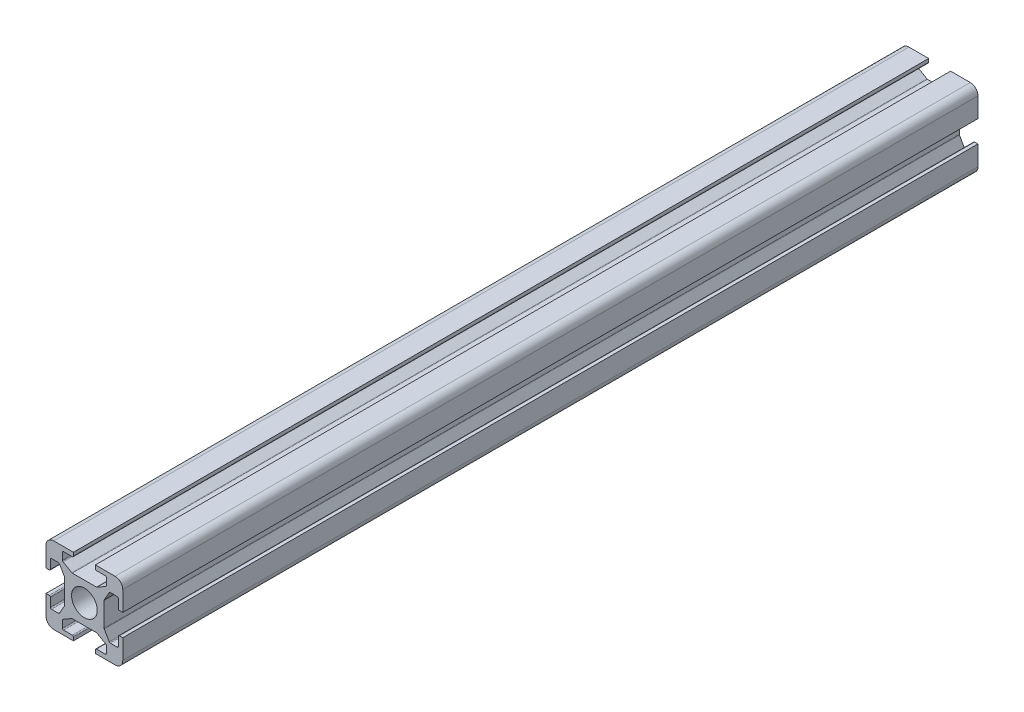
from build123d import *

# Parameters (mm, degrees)
CROQUIS1_R              = 5.85
SALIENTE_EXTRUIR1_DEPTH = 390


with BuildPart() as part:
    # Croquis1 → Saliente-Extruir1 (new body)
    with BuildSketch(Plane.XY):
        with BuildLine():
            Line((-17.5, -5), (-16, -5))
            ThreePointArc((-16, -5), (-15.646446609, -5.146446609), (-15.5, -5.5))
            Line((-15.5, -5.5), (-15.5, -9.5))
            ThreePointArc((-15.5, -9.5), (-15.353553391, -9.853553391), (-15, -10))
            Line((-15, -10), (-11.790147321, -10))
            ThreePointArc((-11.790147321, -10), (-11.539192936, -9.932460283), (-11.356036103, -9.748087586))
            Line((-11.356036103, -9.748087586), (-9.065888782, -5.740718013))
            ThreePointArc((-9.065888782, -5.740718013), (-9.016752854, -5.620974478), (-9, -5.492630427))
            Line((-9, -5.492630427), (-9, 5.492630427))
            ThreePointArc((-9, 5.492630427), (-9.016752854, 5.620974478), (-9.065888782, 5.740718013))
            Line((-9.065888782, 5.740718013), (-11.356036103, 9.748087586))
            ThreePointArc((-11.356036103, 9.748087586), (-11.539192936, 9.932460283), (-11.790147321, 10))
            Line((-11.790147321, 10), (-15, 10))
            ThreePointArc((-15, 10), (-15.353553391, 9.853553391), (-15.5, 9.5))
            Line((-15.5, 9.5), (-15.5, 5.5))
            ThreePointArc((-15.5, 5.5), (-15.646446609, 5.146446609), (-16, 5))
            Line((-16, 5), (-17.5, 5))
            Line((-17.5, 5), (-17.5, 14))
            ThreePointArc((-17.5, 14), (-16.474873734, 16.474873734), (-14, 17.5))
            Line((-14, 17.5), (-5, 17.5))
            Line((-5, 17.5), (-5, 16))
            ThreePointArc((-5, 16), (-5.146446609, 15.646446609), (-5.5, 15.5))
            Line((-5.5, 15.5), (-9.5, 15.5))
            ThreePointArc((-9.5, 15.5), (-9.853553391, 15.353553391), (-10, 15))
            Line((-10, 15), (-10, 11.790147321))
            ThreePointArc((-10, 11.790147321), (-9.932460283, 11.539192936), (-9.748087586, 11.356036103))
            Line((-9.748087586, 11.356036103), (-5.740718013, 9.065888782))
            ThreePointArc((-5.740718013, 9.065888782), (-5.620974478, 9.016752854), (-5.492630427, 9))
            Line((-5.492630427, 9), (5.492630427, 9))
            ThreePointArc((5.492630427, 9), (5.620974478, 9.016752854), (5.740718013, 9.065888782))
            Line((5.740718013, 9.065888782), (9.748087586, 11.356036103))
            ThreePointArc((9.748087586, 11.356036103), (9.932460283, 11.539192936), (10, 11.790147321))
            Line((10, 11.790147321), (10, 15))
            ThreePointArc((10, 15), (9.853553391, 15.353553391), (9.5, 15.5))
            Line((9.5, 15.5), (5.5, 15.5))
            ThreePointArc((5.5, 15.5), (5.146446609, 15.646446609), (5, 16))
            Line((5, 16), (5, 17.5))
            Line((5, 17.5), (14, 17.5))
            ThreePointArc((14, 17.5), (16.474873734, 16.474873734), (17.5, 14))
            Line((17.5, 14), (17.5, 5))
            Line((17.5, 5), (16, 5))
            ThreePointArc((16, 5), (15.646446609, 5.146446609), (15.5, 5.5))
            Line((15.5, 5.5), (15.5, 9.5))
            ThreePointArc((15.5, 9.5), (15.353553391, 9.853553391), (15, 10))
            Line((15, 10), (11.790147321, 10))
            ThreePointArc((11.790147321, 10), (11.539192936, 9.932460283), (11.356036103, 9.748087586))
            Line((11.356036103, 9.748087586), (9.065888782, 5.740718013))
            ThreePointArc((9.065888782, 5.740718013), (9.016752854, 5.620974478), (9, 5.492630427))
            Line((9, 5.492630427), (9, -5.492630427))
            ThreePointArc((9, -5.492630427), (9.016752854, -5.620974478), (9.065888782, -5.740718013))
            Line((9.065888782, -5.740718013), (11.356036103, -9.748087586))
            ThreePointArc((11.356036103, -9.748087586), (11.539192936, -9.932460283), (11.790147321, -10))
            Line((11.790147321, -10), (15, -10))
            ThreePointArc((15, -10), (15.353553391, -9.853553391), (15.5, -9.5))
            Line((15.5, -9.5), (15.5, -5.5))
            ThreePointArc((15.5, -5.5), (15.646446609, -5.146446609), (16, -5))
            Line((16, -5), (17.5, -5))
            Line((17.5, -5), (17.5, -14))
            ThreePointArc((17.5, -14), (16.474873734, -16.474873734), (14, -17.5))
            Line((14, -17.5), (5, -17.5))
            Line((5, -17.5), (5, -16))
            ThreePointArc((5, -16), (5.146446609, -15.646446609), (5.5, -15.5))
            Line((5.5, -15.5), (9.5, -15.5))
            ThreePointArc((9.5, -15.5), (9.853553391, -15.353553391), (10, -15))
            Line((10, -15), (10, -11.790147321))
            ThreePointArc((10, -11.790147321), (9.932460283, -11.539192936), (9.748087586, -11.356036103))
            Line((9.748087586, -11.356036103), (5.740718013, -9.065888782))
            ThreePointArc((5.740718013, -9.065888782), (5.620974478, -9.016752854), (5.492630427, -9))
            Line((5.492630427, -9), (-5.492630427, -9))
            ThreePointArc((-5.492630427, -9), (-5.620974478, -9.016752854), (-5.740718013, -9.065888782))
            Line((-5.740718013, -9.065888782), (-9.748087586, -11.356036103))
            ThreePointArc((-9.748087586, -11.356036103), (-9.932460283, -11.539192936), (-10, -11.790147321))
            Line((-10, -11.790147321), (-10, -15))
            ThreePointArc((-10, -15), (-9.853553391, -15.353553391), (-9.5, -15.5))
            Line((-9.5, -15.5), (-5.5, -15.5))
            ThreePointArc((-5.5, -15.5), (-5.146446609, -15.646446609), (-5, -16))
            Line((-5, -16), (-5, -17.5))
            Line((-5, -17.5), (-14, -17.5))
            ThreePointArc((-14, -17.5), (-16.474873734, -16.474873734), (-17.5, -14))
            Line((-17.5, -14), (-17.5, -5))
        make_face()
        Circle(CROQUIS1_R, mode=Mode.SUBTRACT)
    extrude(amount=SALIENTE_EXTRUIR1_DEPTH)


solid = part.part
